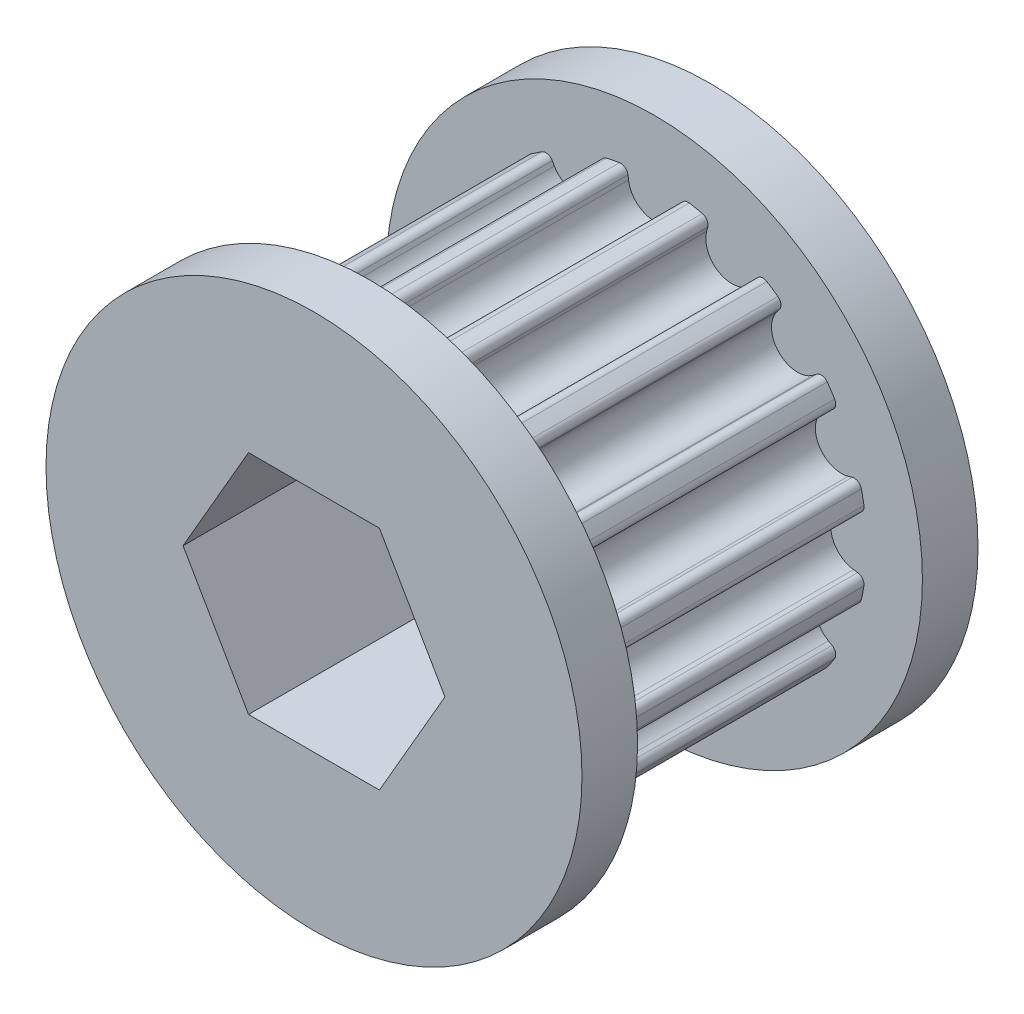
from build123d import *

# Parameters (mm, degrees)
SKETCH1_W           = 15.307395447
SKETCH1_H           = 3.175
BOSS_EXTRUDE1_DEPTH = 16.27
SKETCH3_R           = 15.307395447
BOSS_EXTRUDE2_DEPTH = 3.175
CUT_EXTRUDE1_DEPTH  = 23.62
FILLET1_R           = 0.42


with BuildPart() as part:
    # Sketch1 → Revolve1 (revolve)
    with BuildSketch(Plane.XZ):
        with Locations((7.653697724, 1.5875)):
            Rectangle(SKETCH1_W, SKETCH1_H)
    revolve(axis=Axis((0, 0, 3.175), (0, 0, -1)))

    # Sketch2 → Boss-Extrude1 (add)
    with BuildSketch(Plane.XY.offset(3.175)):
        with BuildLine():
            Line((1.563453637, -12.031235681), (1.477576398, -11.370385062))
            ThreePointArc((1.477576398, -11.370385062), (0, -10.072395447), (-1.477576398, -11.370385062))
            Line((-1.477576398, -11.370385062), (-1.563453637, -12.031235681))
            ThreePointArc((-1.563453637, -12.031235681), (-2.366912935, -11.899274871), (-3.159711751, -11.713720201))
            Line((-3.159711751, -11.713720201), (-2.986155391, -11.070310044))
            ThreePointArc((-2.986155391, -11.070310044), (-3.854538862, -9.305679997), (-5.716360575, -9.939422028))
            Line((-5.716360575, -9.939422028), (-6.048597381, -10.517104592))
            ThreePointArc((-6.048597381, -10.517104592), (-6.740397766, -10.087718139), (-7.401839667, -9.612897005))
            Line((-7.401839667, -9.612897005), (-6.995272092, -9.084880673))
            ThreePointArc((-6.995272092, -9.084880673), (-7.122259124, -7.122259124), (-9.084880673, -6.995272092))
            Line((-9.084880673, -6.995272092), (-9.612897005, -7.401839667))
            ThreePointArc((-9.612897005, -7.401839667), (-10.087718139, -6.740397766), (-10.517104592, -6.048597381))
            Line((-10.517104592, -6.048597381), (-9.939422028, -5.716360575))
            ThreePointArc((-9.939422028, -5.716360575), (-9.305679997, -3.854538862), (-11.070310044, -2.986155391))
            Line((-11.070310044, -2.986155391), (-11.713720201, -3.159711751))
            ThreePointArc((-11.713720201, -3.159711751), (-11.899274871, -2.366912935), (-12.031235681, -1.563453637))
            Line((-12.031235681, -1.563453637), (-11.370385062, -1.477576398))
            ThreePointArc((-11.370385062, -1.477576398), (-10.072395447, 0), (-11.370385062, 1.477576398))
            Line((-11.370385062, 1.477576398), (-12.031235681, 1.563453637))
            ThreePointArc((-12.031235681, 1.563453637), (-11.899274871, 2.366912935), (-11.713720201, 3.159711751))
            Line((-11.713720201, 3.159711751), (-11.070310044, 2.986155391))
            ThreePointArc((-11.070310044, 2.986155391), (-9.305679997, 3.854538862), (-9.939422028, 5.716360575))
            Line((-9.939422028, 5.716360575), (-10.517104592, 6.048597381))
            ThreePointArc((-10.517104592, 6.048597381), (-10.087718139, 6.740397766), (-9.612897005, 7.401839667))
            Line((-9.612897005, 7.401839667), (-9.084880673, 6.995272092))
            ThreePointArc((-9.084880673, 6.995272092), (-7.122259124, 7.122259124), (-6.995272092, 9.084880673))
            Line((-6.995272092, 9.084880673), (-7.401839667, 9.612897005))
            ThreePointArc((-7.401839667, 9.612897005), (-6.740397766, 10.087718139), (-6.048597381, 10.517104592))
            Line((-6.048597381, 10.517104592), (-5.716360575, 9.939422028))
            ThreePointArc((-5.716360575, 9.939422028), (-3.854538862, 9.305679997), (-2.986155391, 11.070310044))
            Line((-2.986155391, 11.070310044), (-3.159711751, 11.713720201))
            ThreePointArc((-3.159711751, 11.713720201), (-2.366912935, 11.899274871), (-1.563453637, 12.031235681))
            Line((-1.563453637, 12.031235681), (-1.477576398, 11.370385062))
            ThreePointArc((-1.477576398, 11.370385062), (0, 10.072395447), (1.477576398, 11.370385062))
            Line((1.477576398, 11.370385062), (1.563453637, 12.031235681))
            ThreePointArc((1.563453637, 12.031235681), (2.366912935, 11.899274871), (3.159711751, 11.713720201))
            Line((3.159711751, 11.713720201), (2.986155391, 11.070310044))
            ThreePointArc((2.986155391, 11.070310044), (3.854538862, 9.305679997), (5.716360575, 9.939422028))
            Line((5.716360575, 9.939422028), (6.048597381, 10.517104592))
            ThreePointArc((6.048597381, 10.517104592), (6.740397766, 10.087718139), (7.401839667, 9.612897005))
            Line((7.401839667, 9.612897005), (6.995272092, 9.084880673))
            ThreePointArc((6.995272092, 9.084880673), (7.122259124, 7.122259124), (9.084880673, 6.995272092))
            Line((9.084880673, 6.995272092), (9.612897005, 7.401839667))
            ThreePointArc((9.612897005, 7.401839667), (10.087718139, 6.740397766), (10.517104592, 6.048597381))
            Line((10.517104592, 6.048597381), (9.939422028, 5.716360575))
            ThreePointArc((9.939422028, 5.716360575), (9.305679997, 3.854538862), (11.070310044, 2.986155391))
            Line((11.070310044, 2.986155391), (11.713720201, 3.159711751))
            ThreePointArc((11.713720201, 3.159711751), (11.899274871, 2.366912935), (12.031235681, 1.563453637))
            Line((12.031235681, 1.563453637), (11.370385062, 1.477576398))
            ThreePointArc((11.370385062, 1.477576398), (10.072395447, 0), (11.370385062, -1.477576398))
            Line((11.370385062, -1.477576398), (12.031235681, -1.563453637))
            ThreePointArc((12.031235681, -1.563453637), (11.899274871, -2.366912935), (11.713720201, -3.159711751))
            Line((11.713720201, -3.159711751), (11.070310044, -2.986155391))
            ThreePointArc((11.070310044, -2.986155391), (9.305679997, -3.854538862), (9.939422028, -5.716360575))
            Line((9.939422028, -5.716360575), (10.517104592, -6.048597381))
            ThreePointArc((10.517104592, -6.048597381), (10.087718139, -6.740397766), (9.612897005, -7.401839667))
            Line((9.612897005, -7.401839667), (9.084880673, -6.995272092))
            ThreePointArc((9.084880673, -6.995272092), (7.122259124, -7.122259124), (6.995272092, -9.084880673))
            Line((6.995272092, -9.084880673), (7.401839667, -9.612897005))
            ThreePointArc((7.401839667, -9.612897005), (6.740397766, -10.087718139), (6.048597381, -10.517104592))
            Line((6.048597381, -10.517104592), (5.716360575, -9.939422028))
            ThreePointArc((5.716360575, -9.939422028), (3.854538862, -9.305679997), (2.986155391, -11.070310044))
            Line((2.986155391, -11.070310044), (3.159711751, -11.713720201))
            ThreePointArc((3.159711751, -11.713720201), (2.366912935, -11.899274871), (1.563453637, -12.031235681))
        make_face()
    extrude(amount=BOSS_EXTRUDE1_DEPTH)

    # Sketch3 → Boss-Extrude2 (add)
    with BuildSketch(Plane(origin=(0, 0, 19.445), x_dir=(-1, 0, 0), z_dir=(0, 0, -1))):
        Circle(SKETCH3_R)
    extrude(amount=-BOSS_EXTRUDE2_DEPTH)

    # Sketch4 → Cut-Extrude1 (cut, through all)
    with BuildSketch(Plane.XY.offset(22.62)):
        Polygon((-7.478995387, 0), (-3.739497694, -6.477), (3.739497694, -6.477), (7.478995387, 0), (3.739497694, 6.477), (-3.739497694, 6.477), align=None)
    extrude(amount=-CUT_EXTRUDE1_DEPTH, mode=Mode.SUBTRACT)

    # Fillet1
    fillet1_edges = [part.edges().sort_by_distance(p)[0] for p in [
        (1.563453637, -12.031235681, 11.31),
        (3.159711751, -11.713720201, 11.31),
        (6.048597381, -10.517104592, 11.31),
        (7.401839667, -9.612897005, 11.31),
        (9.612897005, -7.401839667, 11.31),
        (10.517104592, -6.048597381, 11.31),
        (11.713720201, -3.159711751, 11.31),
        (12.031235681, -1.563453637, 11.31),
        (12.031235681, 1.563453637, 11.31),
        (11.713720201, 3.159711751, 11.31),
        (10.517104592, 6.048597381, 11.31),
        (9.612897005, 7.401839667, 11.31),
        (7.401839667, 9.612897005, 11.31),
        (6.048597381, 10.517104592, 11.31),
        (3.159711751, 11.713720201, 11.31),
        (1.563453637, 12.031235681, 11.31),
        (-1.563453637, 12.031235681, 11.31),
        (-3.159711751, 11.713720201, 11.31),
        (-6.048597381, 10.517104592, 11.31),
        (-7.401839667, 9.612897005, 11.31),
        (-9.612897005, 7.401839667, 11.31),
        (-10.517104592, 6.048597381, 11.31),
        (-11.713720201, 3.159711751, 11.31),
        (-12.031235681, 1.563453637, 11.31),
        (-12.031235681, -1.563453637, 11.31),
        (-11.713720201, -3.159711751, 11.31),
        (-10.517104592, -6.048597381, 11.31),
        (-9.612897005, -7.401839667, 11.31),
        (-7.401839667, -9.612897005, 11.31),
        (-6.048597381, -10.517104592, 11.31),
        (-3.159711751, -11.713720201, 11.31),
        (-1.563453637, -12.031235681, 11.31),
    ]]
    fillet(fillet1_edges, radius=FILLET1_R)


solid = part.part
